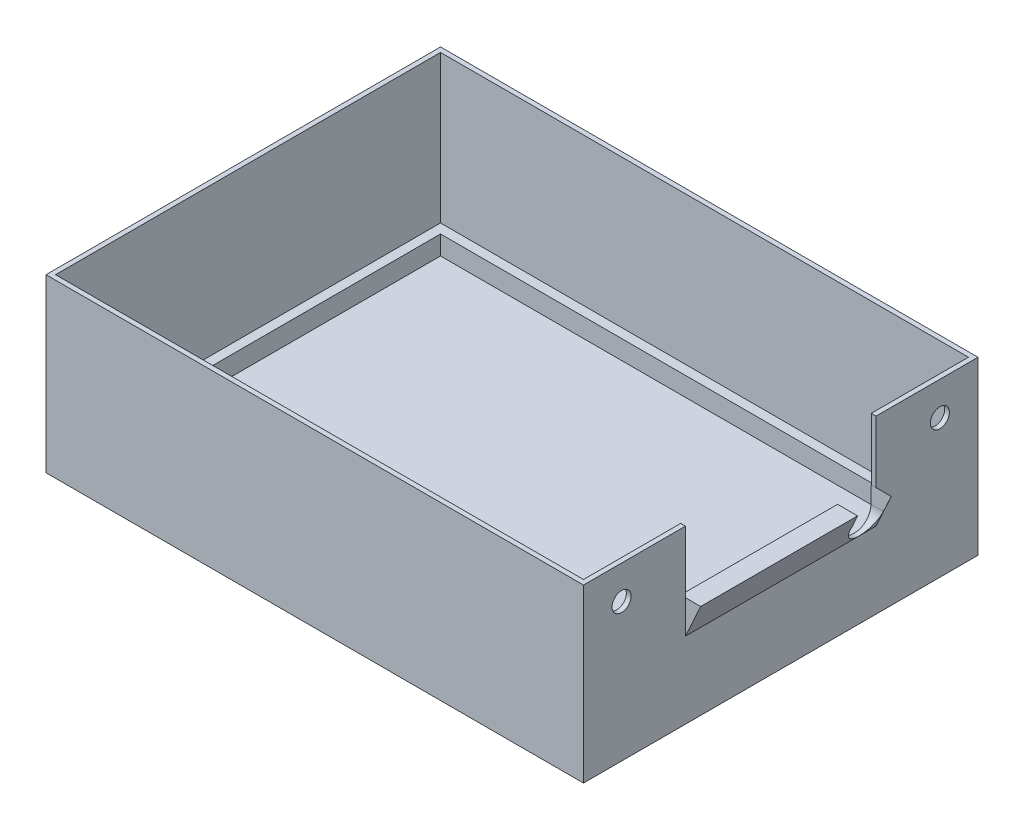
from build123d import *

# Parameters (mm, degrees)
SKETCH1_W           = 112.8
SKETCH1_H           = 82.8
BOSS_EXTRUDE2_DEPTH = 36
SHELL1_T            = -1
SKETCH2_W           = 110.8
SKETCH2_H           = 80.8
SKETCH2_W_2         = 106.8
SKETCH2_H_2         = 76.8
BOSS_EXTRUDE3_DEPTH = 4
CUT_EXTRUDE1_REACH  = 114.8
SKETCH3_W           = 40
SKETCH3_H           = 13
BOSS_EXTRUDE4_DEPTH = 40
CUT_EXTRUDE2_REACH  = 6.2
CUT_EXTRUDE3_REACH  = 114.8
SKETCH7_R           = 2


with BuildPart() as part:
    # Sketch1 → Boss-Extrude2 (new body)
    with BuildSketch(Plane(origin=(0, 0, 0), x_dir=(1, 0, 0), z_dir=(0, 1, 0))):
        with Locations((-33.395774648, 2.631690141)):
            Rectangle(SKETCH1_W, SKETCH1_H)
    extrude(amount=BOSS_EXTRUDE2_DEPTH)

    # Shell1
    shell1_openings = [part.faces().sort_by_distance(p)[0] for p in [
        (-33.395774648, 36, -2.631690141),
    ]]
    offset(amount=SHELL1_T, openings=shell1_openings, kind=Kind.INTERSECTION)

    # Sketch2 → Boss-Extrude3 (add)
    with BuildSketch(Plane(origin=(0, 1, 0), x_dir=(1, 0, 0), z_dir=(0, 1, 0))):
        with Locations((-33.395774648, 2.631690141)):
            Rectangle(SKETCH2_W, SKETCH2_H)
        with Locations((-33.395774648, 2.631690141)):
            Rectangle(SKETCH2_W_2, SKETCH2_H_2, mode=Mode.SUBTRACT)
    extrude(amount=BOSS_EXTRUDE3_DEPTH)

    # Sketch3 → Cut-Extrude1 (cut, up to next)
    with BuildSketch(Plane(origin=(23.004225352, 0, 0), x_dir=(0, 0, -1), z_dir=(1, 0, 0)), mode=Mode.PRIVATE) as cut_extrude1_sk1:
        with Locations((2.631690141, 29.5)):
            Rectangle(SKETCH3_W, SKETCH3_H)
    cut_extrude1_tool1 = extrude(cut_extrude1_sk1.sketch, amount=-CUT_EXTRUDE1_REACH, mode=Mode.PRIVATE) & part.part
    add(cut_extrude1_tool1.solids().sort_by_distance((23.004225, 29.5, -2.63169))[0], mode=Mode.SUBTRACT)

    # Sketch4 → Boss-Extrude4 (add)
    with BuildSketch(Plane.XY.offset(-22.631690141)):
        Polygon((23.004225352, 23), (23.004225352, 16), (26.204225352, 23), align=None)
    extrude(amount=BOSS_EXTRUDE4_DEPTH)

    # Sketch6 → Cut-Extrude2 (cut, up to next)
    with BuildSketch(Plane.ZY.offset(-22.004225352), mode=Mode.PRIVATE) as cut_extrude2_sk1:
        with BuildLine():
            Line((-22.631690141, 23), (-22.560496611, 19.5))
            ThreePointArc((-22.560496611, 19.5), (-19.060496611, 16), (-15.560496611, 19.5))
            Line((-15.560496611, 19.5), (-15.560496611, 23))
            Line((-15.560496611, 23), (-22.631690141, 23))
        make_face()
    cut_extrude2_tool1 = extrude(cut_extrude2_sk1.sketch, amount=-CUT_EXTRUDE2_REACH, mode=Mode.PRIVATE) & part.part
    add(cut_extrude2_tool1.solids().sort_by_distance((22.004225, 19.832424, -19.070505))[0], mode=Mode.SUBTRACT)

    # Sketch7 → Cut-Extrude3 (cut, up to next)
    with BuildSketch(Plane(origin=(23.004225352, 0, 0), x_dir=(0, 0, -1), z_dir=(1, 0, 0)), mode=Mode.PRIVATE) as cut_extrude3_sk1:
        with Locations((36.031690141, 29)):
            Circle(SKETCH7_R)
    cut_extrude3_tool1 = extrude(cut_extrude3_sk1.sketch, amount=-CUT_EXTRUDE3_REACH, mode=Mode.PRIVATE) & part.part
    add(cut_extrude3_tool1.solids().sort_by_distance((23.004225, 29, -36.03169))[0], mode=Mode.SUBTRACT)
    # Sketch7 → Cut-Extrude3 (cut, up to next)
    with BuildSketch(Plane(origin=(23.004225352, 0, 0), x_dir=(0, 0, -1), z_dir=(1, 0, 0)), mode=Mode.PRIVATE) as cut_extrude3_sk2:
        with Locations((-30.768309859, 29)):
            Circle(SKETCH7_R)
    cut_extrude3_tool2 = extrude(cut_extrude3_sk2.sketch, amount=-CUT_EXTRUDE3_REACH, mode=Mode.PRIVATE) & part.part
    add(cut_extrude3_tool2.solids().sort_by_distance((23.004225, 29, 30.76831))[0], mode=Mode.SUBTRACT)


solid = part.part
